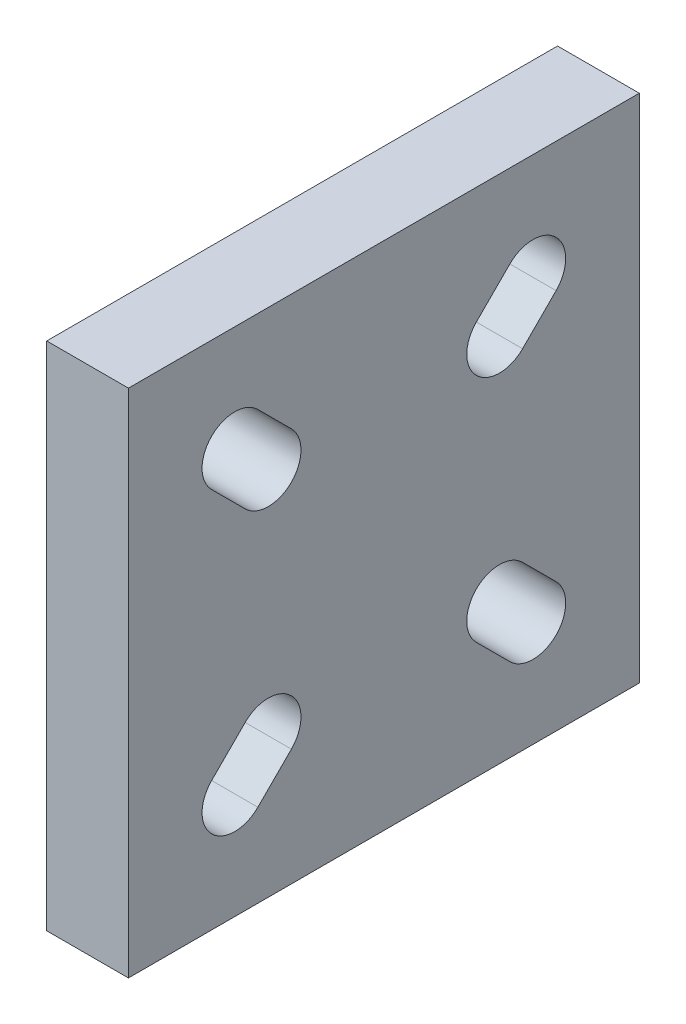
from build123d import *

# Parameters (mm, degrees)
SKETCH2_W           = 25
SKETCH2_H           = 25
BOSS_EXTRUDE1_DEPTH = 4


with BuildPart() as part:
    # Sketch2 → Boss-Extrude1 (new body)
    with BuildSketch(Plane(origin=(0, 0, 0), x_dir=(0, 0, -1), z_dir=(1, 0, 0))):
        Rectangle(SKETCH2_W, SKETCH2_H)
        with BuildLine():
            Line((-4.5254834, -6.788225099), (-6.166074019, -8.428815718))
            ThreePointArc((-6.166074019, -8.428815718), (-8.428815718, -8.428815718), (-8.428815718, -6.166074019))
            Line((-8.428815718, -6.166074019), (-6.788225099, -4.5254834))
            ThreePointArc((-6.788225099, -4.5254834), (-4.5254834, -4.5254834), (-4.5254834, -6.788225099))
        make_face(mode=Mode.SUBTRACT)
        with BuildLine():
            Line((6.788225099, -4.5254834), (8.428815718, -6.166074019))
            ThreePointArc((8.428815718, -6.166074019), (8.428815718, -8.428815718), (6.166074019, -8.428815718))
            Line((6.166074019, -8.428815718), (4.5254834, -6.788225099))
            ThreePointArc((4.5254834, -6.788225099), (4.5254834, -4.5254834), (6.788225099, -4.5254834))
        make_face(mode=Mode.SUBTRACT)
        with BuildLine():
            Line((-6.788225099, 4.5254834), (-8.428815718, 6.166074019))
            ThreePointArc((-8.428815718, 6.166074019), (-8.428815718, 8.428815718), (-6.166074019, 8.428815718))
            Line((-6.166074019, 8.428815718), (-4.5254834, 6.788225099))
            ThreePointArc((-4.5254834, 6.788225099), (-4.5254834, 4.5254834), (-6.788225099, 4.5254834))
        make_face(mode=Mode.SUBTRACT)
        with BuildLine():
            Line((4.5254834, 6.788225099), (6.166074019, 8.428815718))
            ThreePointArc((6.166074019, 8.428815718), (8.428815718, 8.428815718), (8.428815718, 6.166074019))
            Line((8.428815718, 6.166074019), (6.788225099, 4.5254834))
            ThreePointArc((6.788225099, 4.5254834), (4.5254834, 4.5254834), (4.5254834, 6.788225099))
        make_face(mode=Mode.SUBTRACT)
    extrude(amount=BOSS_EXTRUDE1_DEPTH)


solid = part.part
